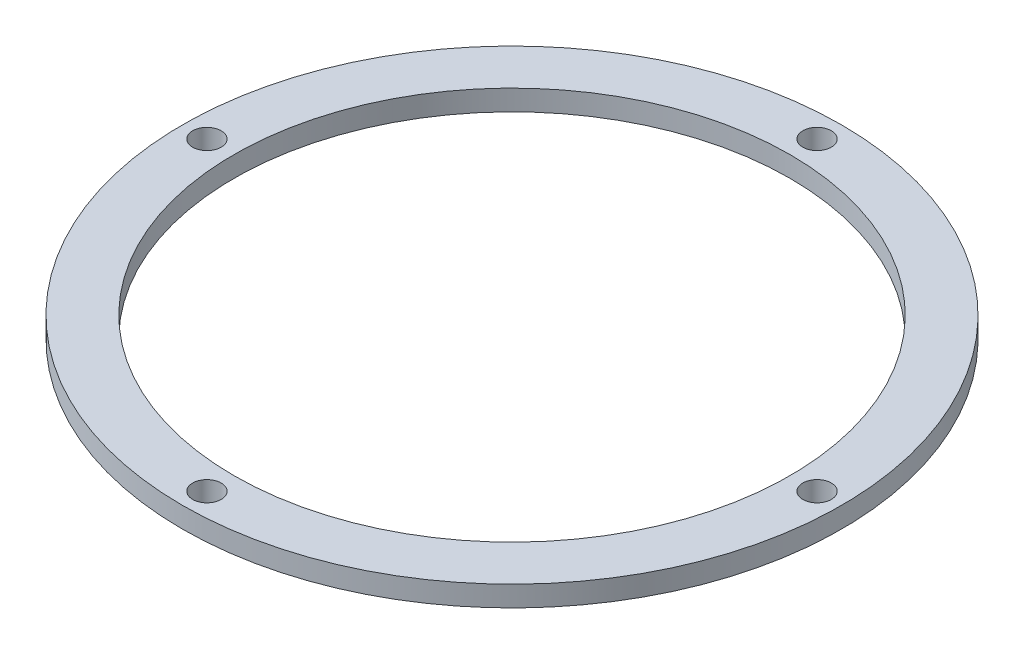
from build123d import *

# Parameters (mm, degrees)
SKETCH1_R           = 101.6
SKETCH1_R_2         = 4.399999963
SKETCH1_R_3         = 85.725
BOSS_EXTRUDE1_DEPTH = 6.35


with BuildPart() as part:
    # Sketch1 → Boss-Extrude1 (new body)
    with BuildSketch(Plane(origin=(0, 0, 0), x_dir=(1, 0, 0), z_dir=(0, 1, 0))):
        Circle(SKETCH1_R)
        with Locations((0, -94.0452)):
            Circle(SKETCH1_R_2, mode=Mode.SUBTRACT)
        with Locations((94.0452, 0)):
            Circle(SKETCH1_R_2, mode=Mode.SUBTRACT)
        with Locations((-94.0452, 0)):
            Circle(SKETCH1_R_2, mode=Mode.SUBTRACT)
        Circle(SKETCH1_R_3, mode=Mode.SUBTRACT)
        with Locations((0, 94.0452)):
            Circle(SKETCH1_R_2, mode=Mode.SUBTRACT)
    extrude(amount=BOSS_EXTRUDE1_DEPTH)


solid = part.part
